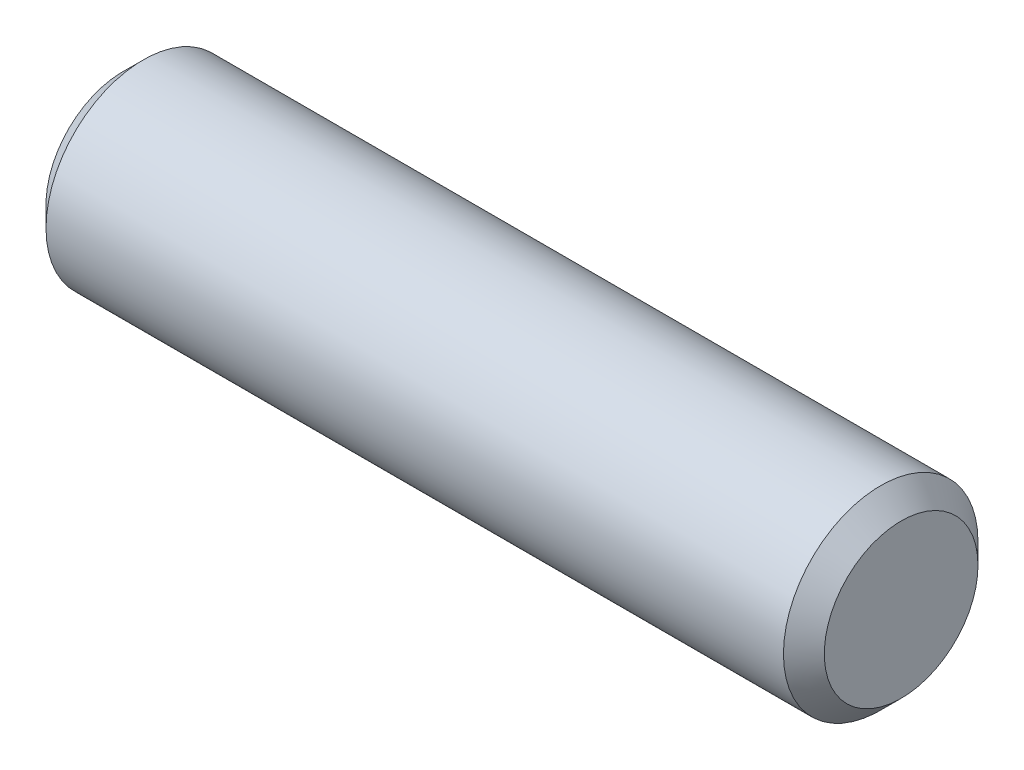
from build123d import *

# Parameters (mm, degrees)
SKETCH2_R           = 1.190625
BOSS_EXTRUDE1_DEPTH = 4.7625
CHAMFER1_SIZE       = 0.25


with BuildPart() as part:
    # Sketch2 → Boss-Extrude1 (new body, symmetric)
    with BuildSketch(Plane(origin=(0, 0, 0), x_dir=(0, 0, -1), z_dir=(1, 0, 0))):
        Circle(SKETCH2_R)
    extrude(amount=BOSS_EXTRUDE1_DEPTH, both=True)

    # Chamfer1
    chamfer1_edges = [part.edges().sort_by_distance(p)[0] for p in [
        (-4.7625, 0, 1.190625),
        (4.7625, 0, 1.190625),
    ]]
    chamfer(chamfer1_edges, length=CHAMFER1_SIZE)


solid = part.part
